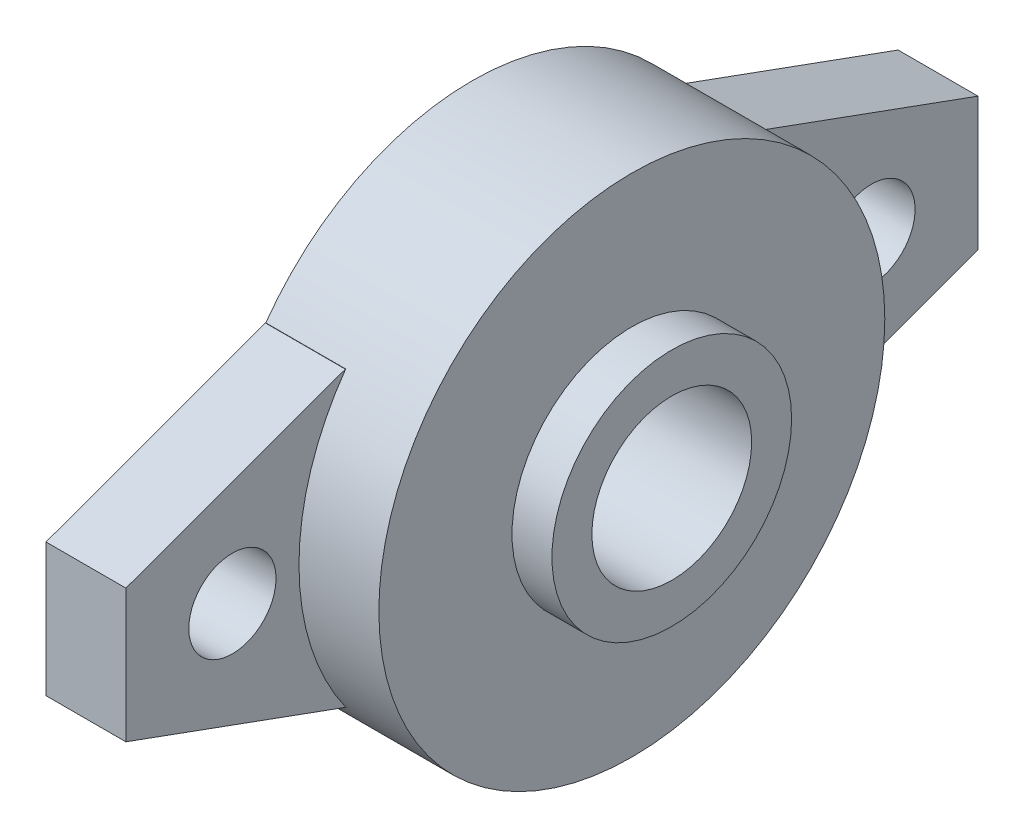
from build123d import *

# Parameters (mm, degrees)
SKETCH1_R             = 19
SKETCH1_R_2           = 6
BOSS_EXTRUDE1_DEPTH   = 12
SKETCH2_R             = 9
SKETCH2_R_2           = 6
BOSS_EXTRUDE2_DEPTH   = 3
SKETCH3_W             = 64
SKETCH3_H             = 22
BOSS_EXTRUDE3_DEPTH   = 6
CHAMFER1_SIZE         = 6
CHAMFER1_SIZE2        = 16.484864517
CHAMFER1_PART_2_SIZE  = 6
CHAMFER1_PART_2_SIZE2 = 16.484864517
SKETCH4_R             = 3.275853321
CUT_EXTRUDE1_DEPTH    = 6
LPATTERN1_COUNT       = 2
LPATTERN1_PITCH       = 48
SKETCH5_R             = 6
CUT_EXTRUDE2_DEPTH    = 6


with BuildPart() as part:
    # Sketch1 → Boss-Extrude1 (new body)
    with BuildSketch(Plane(origin=(0, 0, 0), x_dir=(0, 0, -1), z_dir=(1, 0, 0))):
        Circle(SKETCH1_R)
        Circle(SKETCH1_R_2, mode=Mode.SUBTRACT)
    extrude(amount=BOSS_EXTRUDE1_DEPTH)

    # Sketch2 → Boss-Extrude2 (add)
    with BuildSketch(Plane(origin=(12, 0, 0), x_dir=(0, 0, -1), z_dir=(1, 0, 0))):
        Circle(SKETCH2_R)
        Circle(SKETCH2_R_2, mode=Mode.SUBTRACT)
    extrude(amount=BOSS_EXTRUDE2_DEPTH)

    # Sketch3 → Boss-Extrude3 (add)
    with BuildSketch(Plane.ZY):
        Rectangle(SKETCH3_W, SKETCH3_H)
    extrude(amount=-BOSS_EXTRUDE3_DEPTH)

    # Chamfer1
    chamfer1_edges = [part.edges().sort_by_distance(p)[0] for p in [
        (3, -11, 32),
        (3, 11, 32),
    ]]
    chamfer1_side = [part.faces().sort_by_distance(p)[0] for p in [
        (3, 0, 32),
    ]]
    chamfer(chamfer1_edges, length=CHAMFER1_SIZE, length2=CHAMFER1_SIZE2, reference=chamfer1_side[0])

    # Chamfer1 part 2
    chamfer1_part_2_edges = [part.edges().sort_by_distance(p)[0] for p in [
        (3, 11, -32),
        (3, -11, -32),
    ]]
    chamfer1_part_2_side = [part.faces().sort_by_distance(p)[0] for p in [
        (3, 0, -32),
    ]]
    chamfer(chamfer1_part_2_edges, length=CHAMFER1_PART_2_SIZE, length2=CHAMFER1_PART_2_SIZE2, reference=chamfer1_part_2_side[0])

    # Sketch4 → Cut-Extrude1 (cut)
    with BuildSketch(Plane.ZY):
        with Locations((-24, 0)):
            Circle(SKETCH4_R)
    cut_extrude1 = extrude(amount=-CUT_EXTRUDE1_DEPTH, mode=Mode.SUBTRACT)

    # LPattern1: Cut-Extrude1 ×2
    with Locations(*[(0, 0, i * LPATTERN1_PITCH) for i in range(1, LPATTERN1_COUNT)]):
        add(cut_extrude1, mode=Mode.SUBTRACT)

    # Sketch5 → Cut-Extrude2 (cut)
    with BuildSketch(Plane.ZY):
        Circle(SKETCH5_R)
    extrude(amount=-CUT_EXTRUDE2_DEPTH, mode=Mode.SUBTRACT)


solid = part.part
